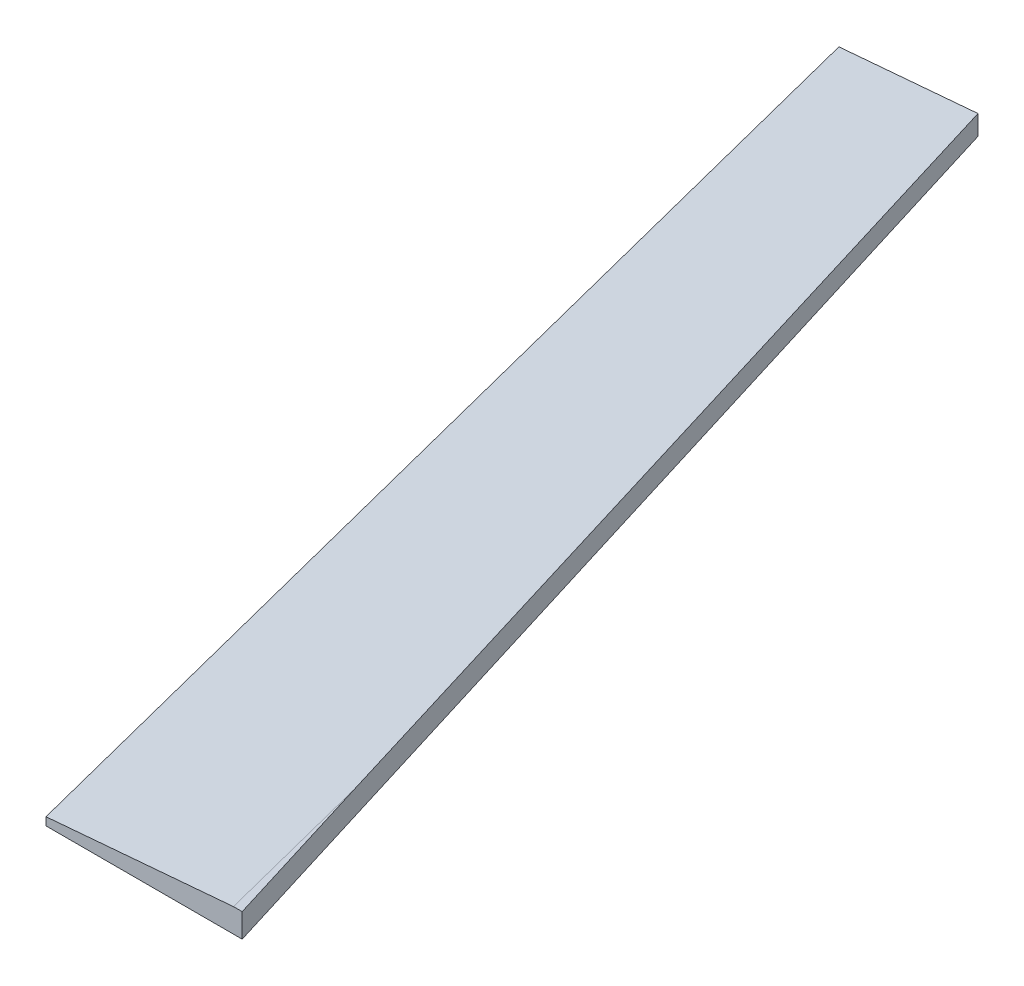
from build123d import *

# Parameters (mm, degrees)
BOSS_EXTRUDE1_DEPTH = 3.81
CHAMFER1_SIZE       = 2.54
CHAMFER1_SIZE2      = 29.032332849


with BuildPart() as part:
    # Sketch2 → Boss-Extrude1 (new body)
    with BuildSketch(Plane(origin=(0, 0, 0), x_dir=(1, 0, 0), z_dir=(0, 1, 0))):
        Polygon((126.581568969, -16.678776649), (178.902552059, -186.601969437), (147.550785663, -186.601969437), (104.349973937, -16.678776649), align=None)
    extrude(amount=BOSS_EXTRUDE1_DEPTH)

    # Chamfer1
    chamfer1_edges = [part.edges().sort_by_distance(p)[0] for p in [
        (125.9503798, 3.81, 101.640373043),
    ]]
    chamfer1_side = [part.faces().sort_by_distance(p)[0] for p in [
        (125.9503798, 1.905, 101.640373043),
    ]]
    chamfer(chamfer1_edges, length=CHAMFER1_SIZE, length2=CHAMFER1_SIZE2, reference=chamfer1_side[0])


solid = part.part
